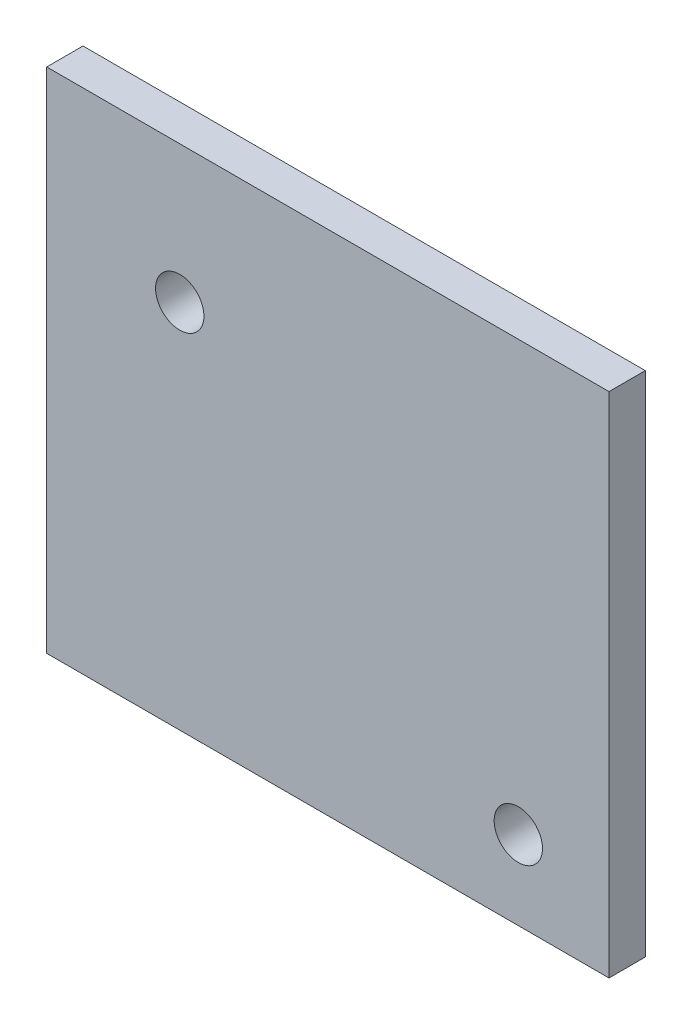
from build123d import *

# Parameters (mm, degrees)
SKETCH1_W           = 46.5
SKETCH1_H           = 42
SKETCH1_R           = 2
BOSS_EXTRUDE1_DEPTH = 3


with BuildPart() as part:
    # Sketch1 → Boss-Extrude1 (new body)
    with BuildSketch(Plane.XY):
        with Locations((1.564019128, -0.092990436)):
            Rectangle(SKETCH1_W, SKETCH1_H)
        with Locations((-10.685980872, 9.555546131)):
            Circle(SKETCH1_R, mode=Mode.SUBTRACT)
        with Locations((17.314019128, -14.572872451)):
            Circle(SKETCH1_R, mode=Mode.SUBTRACT)
    extrude(amount=BOSS_EXTRUDE1_DEPTH)


solid = part.part
